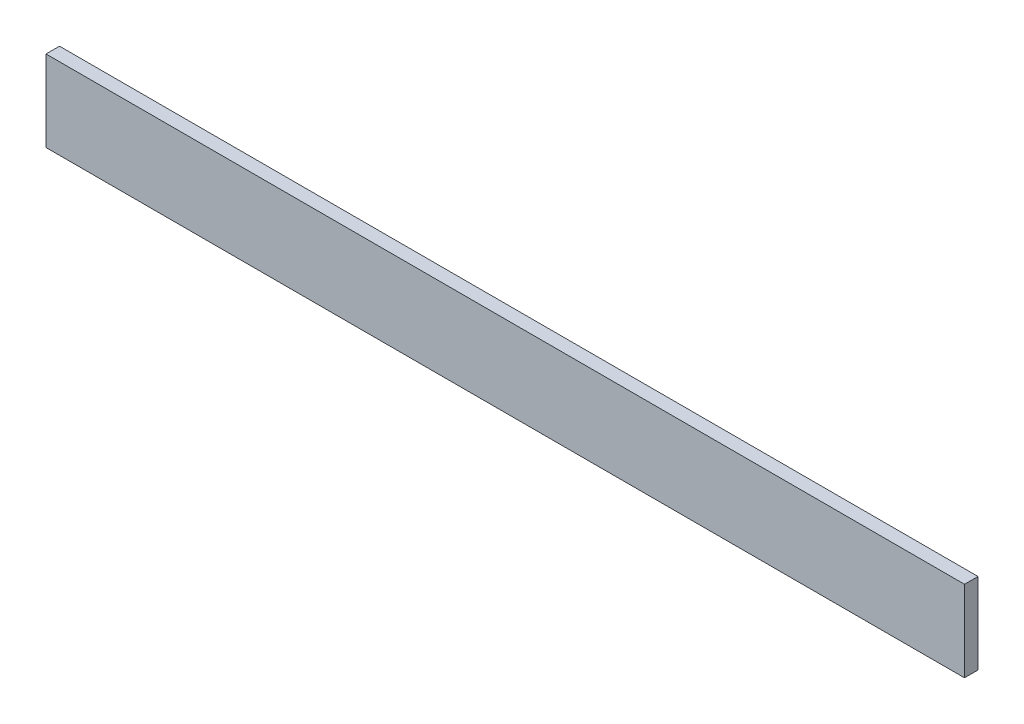
from build123d import *

# Parameters (mm, degrees)
SKETCH1_W           = 215.9
SKETCH1_H           = 19.05
BOSS_EXTRUDE1_DEPTH = 3.175


with BuildPart() as part:
    # Sketch1 → Boss-Extrude1 (new body)
    with BuildSketch(Plane.XY):
        with Locations((6.143495935, 34.064566396)):
            Rectangle(SKETCH1_W, SKETCH1_H)
    extrude(amount=BOSS_EXTRUDE1_DEPTH)


solid = part.part
